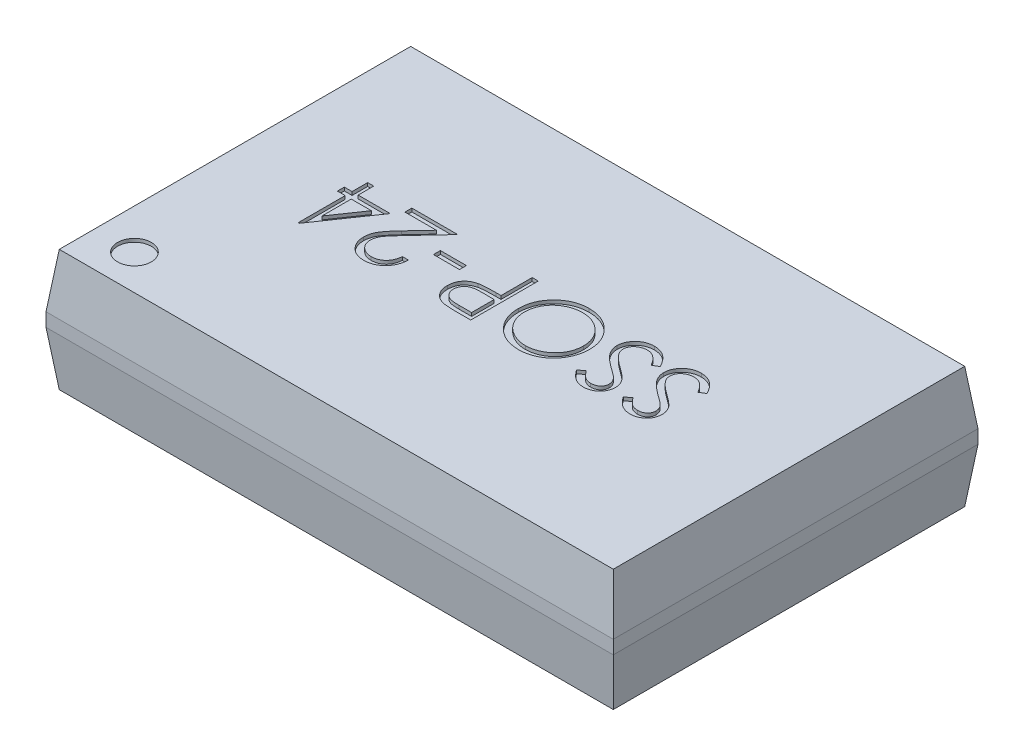
from build123d import *

# Parameters (mm, degrees)
SKETCH1_W             = 8.4
SKETCH1_H             = 5.4
EXTRUDE1_DEPTH        = 1.8
CHAMFER1_SIZE         = 0.8
CHAMFER1_SIZE2        = 0.098227649
CHAMFER1_PART_2_SIZE  = 0.8
CHAMFER1_PART_2_SIZE2 = 0.098227649
CHAMFER1_PART_3_SIZE  = 0.8
CHAMFER1_PART_3_SIZE2 = 0.098227649
CHAMFER1_PART_4_SIZE  = 0.8
CHAMFER1_PART_4_SIZE2 = 0.098227649
CHAMFER2_SIZE         = 0.8
CHAMFER2_SIZE2        = 0.098227649
CHAMFER2_PART_2_SIZE  = 0.8
CHAMFER2_PART_2_SIZE2 = 0.098227649
CHAMFER2_PART_3_SIZE  = 0.8
CHAMFER2_PART_3_SIZE2 = 0.098227649
CHAMFER2_PART_4_SIZE  = 0.8
CHAMFER2_PART_4_SIZE2 = 0.098227649
SKETCH3_R             = 0.25
CUT_EXTRUDE1_DEPTH    = 0.05
SKETCH4_W             = 0.384615385
SKETCH4_H             = 0.102564103
CUT_EXTRUDE2_DEPTH    = 0.05


with BuildPart() as part:
    # Sketch1 → Extrude1 (new body)
    with BuildSketch(Plane(origin=(0, 0, 0), x_dir=(1, 0, 0), z_dir=(0, 1, 0))):
        with Locations((4.2, 2.7)):
            Rectangle(SKETCH1_W, SKETCH1_H)
    extrude(amount=EXTRUDE1_DEPTH)

    # Chamfer1
    chamfer1_edges = [part.edges().sort_by_distance(p)[0] for p in [
        (8.4, 1.8, -2.7),
    ]]
    chamfer1_side = [part.faces().sort_by_distance(p)[0] for p in [
        (8.4, 0.9, -2.7),
    ]]
    chamfer(chamfer1_edges, length=CHAMFER1_SIZE, length2=CHAMFER1_SIZE2, reference=chamfer1_side[0])

    # Chamfer1 part 2
    chamfer1_part_2_edges = [part.edges().sort_by_distance(p)[0] for p in [
        (4.2, 1.8, -5.4),
    ]]
    chamfer1_part_2_side = [part.faces().sort_by_distance(p)[0] for p in [
        (4.2, 0.9, -5.4),
    ]]
    chamfer(chamfer1_part_2_edges, length=CHAMFER1_PART_2_SIZE, length2=CHAMFER1_PART_2_SIZE2, reference=chamfer1_part_2_side[0])

    # Chamfer1 part 3
    chamfer1_part_3_edges = [part.edges().sort_by_distance(p)[0] for p in [
        (0, 1.8, -2.7),
    ]]
    chamfer1_part_3_side = [part.faces().sort_by_distance(p)[0] for p in [
        (0, 0.9, -2.7),
    ]]
    chamfer(chamfer1_part_3_edges, length=CHAMFER1_PART_3_SIZE, length2=CHAMFER1_PART_3_SIZE2, reference=chamfer1_part_3_side[0])

    # Chamfer1 part 4
    chamfer1_part_4_edges = [part.edges().sort_by_distance(p)[0] for p in [
        (4.2, 1.8, 0),
    ]]
    chamfer1_part_4_side = [part.faces().sort_by_distance(p)[0] for p in [
        (4.2, 0.9, 0),
    ]]
    chamfer(chamfer1_part_4_edges, length=CHAMFER1_PART_4_SIZE, length2=CHAMFER1_PART_4_SIZE2, reference=chamfer1_part_4_side[0])

    # Chamfer2
    chamfer2_edges = [part.edges().sort_by_distance(p)[0] for p in [
        (4.2, 0, -5.4),
    ]]
    chamfer2_side = [part.faces().sort_by_distance(p)[0] for p in [
        (4.2, 0.5, -5.4),
    ]]
    chamfer(chamfer2_edges, length=CHAMFER2_SIZE, length2=CHAMFER2_SIZE2, reference=chamfer2_side[0])

    # Chamfer2 part 2
    chamfer2_part_2_edges = [part.edges().sort_by_distance(p)[0] for p in [
        (8.4, 0, -2.7),
    ]]
    chamfer2_part_2_side = [part.faces().sort_by_distance(p)[0] for p in [
        (8.4, 0.5, -2.7),
    ]]
    chamfer(chamfer2_part_2_edges, length=CHAMFER2_PART_2_SIZE, length2=CHAMFER2_PART_2_SIZE2, reference=chamfer2_part_2_side[0])

    # Chamfer2 part 3
    chamfer2_part_3_edges = [part.edges().sort_by_distance(p)[0] for p in [
        (4.2, 0, 0),
    ]]
    chamfer2_part_3_side = [part.faces().sort_by_distance(p)[0] for p in [
        (4.2, 0.5, 0),
    ]]
    chamfer(chamfer2_part_3_edges, length=CHAMFER2_PART_3_SIZE, length2=CHAMFER2_PART_3_SIZE2, reference=chamfer2_part_3_side[0])

    # Chamfer2 part 4
    chamfer2_part_4_edges = [part.edges().sort_by_distance(p)[0] for p in [
        (0, 0, -2.7),
    ]]
    chamfer2_part_4_side = [part.faces().sort_by_distance(p)[0] for p in [
        (0, 0.5, -2.7),
    ]]
    chamfer(chamfer2_part_4_edges, length=CHAMFER2_PART_4_SIZE, length2=CHAMFER2_PART_4_SIZE2, reference=chamfer2_part_4_side[0])

    # Sketch3 → Cut-Extrude1 (cut)
    with BuildSketch(Plane(origin=(0, 1.8, 0), x_dir=(-1, 0, 0), z_dir=(0, 1, 0))):
        with Locations(Location((-0.690878187, -0.618640227, 0), (0, 0, 90))):  # turned: the seam where the file's is
            Circle(SKETCH3_R)
    extrude(amount=-CUT_EXTRUDE1_DEPTH, mode=Mode.SUBTRACT)

    # Sketch4 → Cut-Extrude2 (cut)
    with BuildSketch(Plane(origin=(0, 1.8, 0), x_dir=(-1, 0, 0), z_dir=(0, 1, 0))):
        with BuildLine():
            Line((-6.743449311, -3.044705448), (-6.658914055, -2.994024358))
            add(Edge.make_bspline(
                [(-6.658914055, -2.994024358), (-6.651051701, -3.007185611), (-6.635987735, -3.032402063), (-6.610858776, -3.066475789), (-6.584820801, -3.095436405), (-6.557680991, -3.119115436), (-6.529605006, -3.137757975), (-6.500409562, -3.150958613), (-6.470193045, -3.159191748), (-6.449629096, -3.160191773), (-6.439362773, -3.160691024)],
                knots=[0, 0, 0, 0, 1.272034388, 2.437168799, 3.508375237, 4.49857839, 5.41946034, 6.295179144, 7.148887113, 8, 8, 8, 8], degree=3))
            add(Edge.make_bspline(
                [(-6.439362773, -3.160691024), (-6.430595098, -3.160446832), (-6.413213163, -3.159962721), (-6.387623951, -3.155311063), (-6.362772007, -3.148164741), (-6.339169539, -3.137930189), (-6.317142221, -3.125547764), (-6.297826022, -3.110591713), (-6.281127133, -3.093847083), (-6.267467386, -3.075166325), (-6.256987376, -3.055075711), (-6.248932499, -3.03445401), (-6.244462478, -3.012977277), (-6.24378912, -2.998517144), (-6.243449311, -2.991219871)],
                knots=[0, 0, 0, 0, 1.095163259, 2.171163733, 3.241058638, 4.321873601, 5.38011039, 6.391990106, 7.366004449, 8.327778327, 9.272591725, 10.192022065, 11.087607919, 12, 12, 12, 12], degree=3))
            add(Edge.make_bspline(
                [(-6.243449311, -2.991219871), (-6.243870543, -2.982893914), (-6.244726845, -2.965968459), (-6.251964411, -2.94099713), (-6.26334991, -2.916284967), (-6.273853522, -2.900998891), (-6.279306683, -2.893062819)],
                knots=[0, 0, 0, 0, 0.938893495, 1.908633276, 2.914225137, 4, 4, 4, 4], degree=3))
            add(Edge.make_bspline(
                [(-6.279306683, -2.893062819), (-6.283784001, -2.887335155), (-6.293183571, -2.875310642), (-6.30934286, -2.857412003), (-6.328304607, -2.838949597), (-6.349419909, -2.819218438), (-6.373457934, -2.799136211), (-6.399665795, -2.777745274), (-6.428712612, -2.755859109), (-6.449083897, -2.741181233), (-6.459595144, -2.733607691)],
                knots=[0, 0, 0, 0, 0.722233717, 1.516239348, 2.393582979, 3.351407094, 4.387010283, 5.505090956, 6.712668013, 8, 8, 8, 8], degree=3))
            add(Edge.make_bspline(
                [(-6.459595144, -2.733607691), (-6.470116286, -2.726113809), (-6.490231908, -2.711786077), (-6.518362932, -2.690521996), (-6.543518493, -2.67108089), (-6.565586783, -2.653279744), (-6.584558096, -2.637116142), (-6.600581928, -2.622745303), (-6.613250087, -2.609778571), (-6.620294539, -2.601366759), (-6.623457324, -2.597590063)],
                knots=[0, 0, 0, 0, 1.452282411, 2.77665338, 3.964542531, 5.026858415, 5.96415736, 6.766646006, 7.446254459, 8, 8, 8, 8], degree=3))
            add(Edge.make_bspline(
                [(-6.623457324, -2.597590063), (-6.627878051, -2.591704052), (-6.636572005, -2.580128423), (-6.648048006, -2.562035606), (-6.657802053, -2.543514673), (-6.665448433, -2.524515855), (-6.671887353, -2.505305875), (-6.67621819, -2.485634091), (-6.678930018, -2.465588771), (-6.679207728, -2.452099199), (-6.679346747, -2.445346473)],
                knots=[0, 0, 0, 0, 1.068054152, 2.10047183, 3.106115577, 4.101338837, 5.06977816, 6.043150881, 7.020423561, 8, 8, 8, 8], degree=3))
            add(Edge.make_bspline(
                [(-6.679346747, -2.445346473), (-6.67897383, -2.434766538), (-6.678235967, -2.413832805), (-6.67199582, -2.383252568), (-6.662146421, -2.354056449), (-6.648347882, -2.326533496), (-6.630560067, -2.301400359), (-6.609975503, -2.278367934), (-6.585457935, -2.259005482), (-6.558557186, -2.242087751), (-6.529112508, -2.228846058), (-6.498257964, -2.218857206), (-6.465944515, -2.213197419), (-6.444057905, -2.2123852), (-6.432952516, -2.211973076)],
                knots=[0, 0, 0, 0, 1.005424448, 1.989358655, 2.955360095, 3.929531133, 4.905563448, 5.876582895, 6.856512386, 7.866279853, 8.892233794, 9.918561126, 10.94386622, 12, 12, 12, 12], degree=3))
            add(Edge.make_bspline(
                [(-6.432952516, -2.211973076), (-6.421168488, -2.212379519), (-6.397733816, -2.213187805), (-6.363262611, -2.220215671), (-6.330073835, -2.231844435), (-6.303375759, -2.245041194), (-6.282480685, -2.258221598), (-6.266545618, -2.270227263), (-6.250397775, -2.284048722), (-6.233906902, -2.299722792), (-6.217352428, -2.317393293), (-6.200488585, -2.336939204), (-6.183275937, -2.358241077), (-6.172202834, -2.373448077), (-6.166526234, -2.381243909)],
                knots=[0, 0, 0, 0, 1.286793592, 2.559021753, 3.825965368, 5.121522368, 5.803751409, 6.523245864, 7.299691795, 8.125521123, 9.008227632, 9.944561021, 10.946284179, 12, 12, 12, 12], degree=3))
            Line((-6.166526234, -2.381243909), (-6.247656042, -2.442742306))
            add(Edge.make_bspline(
                [(-6.247656042, -2.442742306), (-6.25255488, -2.436431252), (-6.261988896, -2.424277637), (-6.276311607, -2.407257261), (-6.28981122, -2.391709695), (-6.303111335, -2.378205373), (-6.315509515, -2.366004764), (-6.327542956, -2.355559119), (-6.339038485, -2.346766092), (-6.35352903, -2.337382217), (-6.371734093, -2.328080359), (-6.394586817, -2.320209194), (-6.41846861, -2.315479176), (-6.434734219, -2.31485378), (-6.442968542, -2.314537178)],
                knots=[0, 0, 0, 0, 1.181633172, 2.275549214, 3.290209073, 4.226197932, 5.078386478, 5.862611352, 6.581680152, 7.217281963, 8.414376989, 9.595101626, 10.782541182, 12, 12, 12, 12], degree=3))
            add(Edge.make_bspline(
                [(-6.442968542, -2.314537178), (-6.453298977, -2.314883378), (-6.473220248, -2.315550992), (-6.501503172, -2.322842417), (-6.526958579, -2.334322948), (-6.548830741, -2.350412942), (-6.567041306, -2.369476083), (-6.580214294, -2.391412898), (-6.588142912, -2.415636442), (-6.589110421, -2.432534058), (-6.589603157, -2.441139742)],
                knots=[0, 0, 0, 0, 1.14458467, 2.207223713, 3.21896685, 4.227309161, 5.202851033, 6.127160689, 7.046193047, 8, 8, 8, 8], degree=3))
            add(Edge.make_bspline(
                [(-6.589603157, -2.441139742), (-6.589490835, -2.446497308), (-6.589266008, -2.457221199), (-6.586130351, -2.473064462), (-6.582101972, -2.488867702), (-6.575718363, -2.504559869), (-6.566905419, -2.5204154), (-6.555332511, -2.536707325), (-6.540757279, -2.553579242), (-6.529592419, -2.564552777), (-6.523697709, -2.570346473)],
                knots=[0, 0, 0, 0, 0.858281714, 1.717966888, 2.583508476, 3.4729293, 4.427298488, 5.488583878, 6.674047936, 8, 8, 8, 8], degree=3))
            add(Edge.make_bspline(
                [(-6.523697709, -2.570346473), (-6.521508745, -2.572299909), (-6.516308269, -2.576940826), (-6.506800861, -2.58453862), (-6.494245776, -2.593910841), (-6.478970862, -2.605507217), (-6.460694472, -2.618959063), (-6.439414599, -2.634094381), (-6.415368447, -2.651404512), (-6.398305043, -2.663506667), (-6.389282644, -2.669905768)],
                knots=[0, 0, 0, 0, 0.420754252, 0.999615792, 1.744751191, 2.668019286, 3.750313428, 4.999500688, 6.413464383, 8, 8, 8, 8], degree=3))
            add(Edge.make_bspline(
                [(-6.389282644, -2.669905768), (-6.378429526, -2.677803299), (-6.357413967, -2.693095774), (-6.327511802, -2.716071683), (-6.300399285, -2.738542474), (-6.275981227, -2.760364647), (-6.254016396, -2.781372674), (-6.234748476, -2.801819297), (-6.217981139, -2.821558032), (-6.199929933, -2.846864482), (-6.181484842, -2.877944792), (-6.165644411, -2.916024288), (-6.155656312, -2.954251809), (-6.154350165, -2.97994519), (-6.153705721, -2.992622114)],
                knots=[0, 0, 0, 0, 1.163667725, 2.253281268, 3.268753668, 4.215851969, 5.092017293, 5.902905408, 6.650798638, 7.335211899, 8.59617414, 9.77448103, 10.901945474, 12, 12, 12, 12], degree=3))
            add(Edge.make_bspline(
                [(-6.153705721, -2.992622114), (-6.153893475, -3.001587361), (-6.154265337, -3.019343757), (-6.158539883, -3.045416636), (-6.164802645, -3.070739741), (-6.174241855, -3.095000059), (-6.185762757, -3.11864142), (-6.200381685, -3.141043677), (-6.217326738, -3.162702648), (-6.236764956, -3.183040789), (-6.258035214, -3.20171113), (-6.28051627, -3.218319434), (-6.304244919, -3.232167526), (-6.329092438, -3.243467767), (-6.355064534, -3.252305914), (-6.382152473, -3.258709591), (-6.410400904, -3.262639795), (-6.429601042, -3.263047726), (-6.439362773, -3.263255127)],
                knots=[0, 0, 0, 0, 0.983748083, 1.948392443, 2.894712957, 3.844097841, 4.80183111, 5.778335162, 6.776009319, 7.81870978, 8.863265674, 9.881300176, 10.883814829, 11.87499822, 12.874611388, 13.892143829, 14.928324115, 16, 16, 16, 16], degree=3))
            add(Edge.make_bspline(
                [(-6.439362773, -3.263255127), (-6.446915728, -3.263109075), (-6.461926516, -3.262818811), (-6.484129226, -3.260252731), (-6.505883394, -3.25662213), (-6.526916046, -3.25085811), (-6.547498163, -3.243864688), (-6.56754023, -3.235253735), (-6.58705196, -3.224934535), (-6.606142698, -3.213135957), (-6.624763891, -3.199405172), (-6.642740882, -3.183412745), (-6.660663506, -3.165599743), (-6.678002762, -3.14548244), (-6.695109375, -3.123385844), (-6.711646063, -3.099103221), (-6.727955126, -3.072766834), (-6.738188116, -3.054233952), (-6.743449311, -3.044705448)],
                knots=[0, 0, 0, 0, 0.915332311, 1.819136955, 2.706846663, 3.586547465, 4.459518054, 5.340707479, 6.227863349, 7.133153174, 8.059268498, 9.028702269, 10.047606654, 11.120612155, 12.245963614, 13.433783089, 14.680604001, 16, 16, 16, 16], degree=3))
        make_face()
        with BuildLine():
            Line((-6.051141619, -3.044705448), (-5.966606362, -2.994024358))
            add(Edge.make_bspline(
                [(-5.966606362, -2.994024358), (-5.958744009, -3.007185611), (-5.943680043, -3.032402063), (-5.918551083, -3.066475789), (-5.892513109, -3.095436405), (-5.865373299, -3.119115436), (-5.837297314, -3.137757975), (-5.80810187, -3.150958613), (-5.777885353, -3.159191748), (-5.757321404, -3.160191773), (-5.74705508, -3.160691024)],
                knots=[0, 0, 0, 0, 1.272034388, 2.437168799, 3.508375237, 4.49857839, 5.41946034, 6.295179144, 7.148887113, 8, 8, 8, 8], degree=3))
            add(Edge.make_bspline(
                [(-5.74705508, -3.160691024), (-5.738287406, -3.160446832), (-5.720905471, -3.159962721), (-5.695316259, -3.155311063), (-5.670464315, -3.148164741), (-5.646861847, -3.137930189), (-5.624834529, -3.125547764), (-5.60551833, -3.110591713), (-5.588819441, -3.093847083), (-5.575159693, -3.075166325), (-5.564679683, -3.055075711), (-5.556624807, -3.03445401), (-5.552154786, -3.012977277), (-5.551481428, -2.998517144), (-5.551141619, -2.991219871)],
                knots=[0, 0, 0, 0, 1.095163259, 2.171163733, 3.241058638, 4.321873601, 5.38011039, 6.391990106, 7.366004449, 8.327778327, 9.272591725, 10.192022065, 11.087607919, 12, 12, 12, 12], degree=3))
            add(Edge.make_bspline(
                [(-5.551141619, -2.991219871), (-5.55156285, -2.982893914), (-5.552419153, -2.965968459), (-5.559656719, -2.94099713), (-5.571042218, -2.916284967), (-5.58154583, -2.900998891), (-5.586998991, -2.893062819)],
                knots=[0, 0, 0, 0, 0.938893495, 1.908633276, 2.914225137, 4, 4, 4, 4], degree=3))
            add(Edge.make_bspline(
                [(-5.586998991, -2.893062819), (-5.591476309, -2.887335155), (-5.600875879, -2.875310642), (-5.617035168, -2.857412003), (-5.635996915, -2.838949597), (-5.657112216, -2.819218438), (-5.681150242, -2.799136211), (-5.707358103, -2.777745274), (-5.73640492, -2.755859109), (-5.756776205, -2.741181233), (-5.767287452, -2.733607691)],
                knots=[0, 0, 0, 0, 0.722233717, 1.516239348, 2.393582979, 3.351407094, 4.387010283, 5.505090956, 6.712668013, 8, 8, 8, 8], degree=3))
            add(Edge.make_bspline(
                [(-5.767287452, -2.733607691), (-5.777808594, -2.726113809), (-5.797924216, -2.711786077), (-5.826055239, -2.690521996), (-5.8512108, -2.67108089), (-5.873279091, -2.653279744), (-5.892250404, -2.637116142), (-5.908274236, -2.622745303), (-5.920942395, -2.609778571), (-5.927986847, -2.601366759), (-5.931149632, -2.597590063)],
                knots=[0, 0, 0, 0, 1.452282411, 2.77665338, 3.964542531, 5.026858415, 5.96415736, 6.766646006, 7.446254459, 8, 8, 8, 8], degree=3))
            add(Edge.make_bspline(
                [(-5.931149632, -2.597590063), (-5.935570359, -2.591704052), (-5.944264312, -2.580128423), (-5.955740314, -2.562035606), (-5.96549436, -2.543514673), (-5.973140741, -2.524515855), (-5.979579661, -2.505305875), (-5.983910498, -2.485634091), (-5.986622326, -2.465588771), (-5.986900036, -2.452099199), (-5.987039055, -2.445346473)],
                knots=[0, 0, 0, 0, 1.068054152, 2.10047183, 3.106115577, 4.101338837, 5.06977816, 6.043150881, 7.020423561, 8, 8, 8, 8], degree=3))
            add(Edge.make_bspline(
                [(-5.987039055, -2.445346473), (-5.986666138, -2.434766538), (-5.985928275, -2.413832805), (-5.979688127, -2.383252568), (-5.969838729, -2.354056449), (-5.95604019, -2.326533496), (-5.938252375, -2.301400359), (-5.91766781, -2.278367934), (-5.893150243, -2.259005482), (-5.866249493, -2.242087751), (-5.836804816, -2.228846058), (-5.805950272, -2.218857206), (-5.773636823, -2.213197419), (-5.751750213, -2.2123852), (-5.740644824, -2.211973076)],
                knots=[0, 0, 0, 0, 1.005424448, 1.989358655, 2.955360095, 3.929531133, 4.905563448, 5.876582895, 6.856512386, 7.866279853, 8.892233794, 9.918561126, 10.94386622, 12, 12, 12, 12], degree=3))
            add(Edge.make_bspline(
                [(-5.740644824, -2.211973076), (-5.728860795, -2.212379519), (-5.705426123, -2.213187805), (-5.670954919, -2.220215671), (-5.637766143, -2.231844435), (-5.611068067, -2.245041194), (-5.590172992, -2.258221598), (-5.574237926, -2.270227263), (-5.558090083, -2.284048722), (-5.54159921, -2.299722792), (-5.525044736, -2.317393293), (-5.508180892, -2.336939204), (-5.490968244, -2.358241077), (-5.479895141, -2.373448077), (-5.474218542, -2.381243909)],
                knots=[0, 0, 0, 0, 1.286793592, 2.559021753, 3.825965368, 5.121522368, 5.803751409, 6.523245864, 7.299691795, 8.125521123, 9.008227632, 9.944561021, 10.946284179, 12, 12, 12, 12], degree=3))
            Line((-5.474218542, -2.381243909), (-5.55534835, -2.442742306))
            add(Edge.make_bspline(
                [(-5.55534835, -2.442742306), (-5.560247187, -2.436431252), (-5.569681204, -2.424277637), (-5.584003914, -2.407257261), (-5.597503528, -2.391709695), (-5.610803642, -2.378205373), (-5.623201823, -2.366004764), (-5.635235263, -2.355559119), (-5.646730792, -2.346766092), (-5.661221338, -2.337382217), (-5.6794264, -2.328080359), (-5.702279125, -2.320209194), (-5.726160918, -2.315479176), (-5.742426527, -2.31485378), (-5.75066085, -2.314537178)],
                knots=[0, 0, 0, 0, 1.181633172, 2.275549214, 3.290209073, 4.226197932, 5.078386478, 5.862611352, 6.581680152, 7.217281963, 8.414376989, 9.595101626, 10.782541182, 12, 12, 12, 12], degree=3))
            add(Edge.make_bspline(
                [(-5.75066085, -2.314537178), (-5.760991285, -2.314883378), (-5.780912555, -2.315550992), (-5.80919548, -2.322842417), (-5.834650887, -2.334322948), (-5.856523048, -2.350412942), (-5.874733613, -2.369476083), (-5.887906602, -2.391412898), (-5.89583522, -2.415636442), (-5.896802728, -2.432534058), (-5.897295465, -2.441139742)],
                knots=[0, 0, 0, 0, 1.14458467, 2.207223713, 3.21896685, 4.227309161, 5.202851033, 6.127160689, 7.046193047, 8, 8, 8, 8], degree=3))
            add(Edge.make_bspline(
                [(-5.897295465, -2.441139742), (-5.897183143, -2.446497308), (-5.896958316, -2.457221199), (-5.893822659, -2.473064462), (-5.889794279, -2.488867702), (-5.88341067, -2.504559869), (-5.874597726, -2.5204154), (-5.863024819, -2.536707325), (-5.848449587, -2.553579242), (-5.837284726, -2.564552777), (-5.831390016, -2.570346473)],
                knots=[0, 0, 0, 0, 0.858281714, 1.717966888, 2.583508476, 3.4729293, 4.427298488, 5.488583878, 6.674047936, 8, 8, 8, 8], degree=3))
            add(Edge.make_bspline(
                [(-5.831390016, -2.570346473), (-5.829201053, -2.572299909), (-5.824000576, -2.576940826), (-5.814493169, -2.58453862), (-5.801938084, -2.593910841), (-5.786663169, -2.605507217), (-5.76838678, -2.618959063), (-5.747106907, -2.634094381), (-5.723060755, -2.651404512), (-5.70599735, -2.663506667), (-5.696974952, -2.669905768)],
                knots=[0, 0, 0, 0, 0.420754252, 0.999615792, 1.744751191, 2.668019286, 3.750313428, 4.999500688, 6.413464383, 8, 8, 8, 8], degree=3))
            add(Edge.make_bspline(
                [(-5.696974952, -2.669905768), (-5.686121834, -2.677803299), (-5.665106275, -2.693095774), (-5.635204109, -2.716071683), (-5.608091593, -2.738542474), (-5.583673535, -2.760364647), (-5.561708704, -2.781372674), (-5.542440784, -2.801819297), (-5.525673446, -2.821558032), (-5.507622241, -2.846864482), (-5.48917715, -2.877944792), (-5.473336719, -2.916024288), (-5.46334862, -2.954251809), (-5.462042472, -2.97994519), (-5.461398029, -2.992622114)],
                knots=[0, 0, 0, 0, 1.163667725, 2.253281268, 3.268753668, 4.215851969, 5.092017293, 5.902905408, 6.650798638, 7.335211899, 8.59617414, 9.77448103, 10.901945474, 12, 12, 12, 12], degree=3))
            add(Edge.make_bspline(
                [(-5.461398029, -2.992622114), (-5.461585783, -3.001587361), (-5.461957644, -3.019343757), (-5.466232191, -3.045416636), (-5.472494953, -3.070739741), (-5.481934162, -3.095000059), (-5.493455065, -3.11864142), (-5.508073993, -3.141043677), (-5.525019045, -3.162702648), (-5.544457264, -3.183040789), (-5.565727522, -3.20171113), (-5.588208577, -3.218319434), (-5.611937227, -3.232167526), (-5.636784746, -3.243467767), (-5.662756842, -3.252305914), (-5.68984478, -3.258709591), (-5.718093212, -3.262639795), (-5.73729335, -3.263047726), (-5.74705508, -3.263255127)],
                knots=[0, 0, 0, 0, 0.983748083, 1.948392443, 2.894712957, 3.844097841, 4.80183111, 5.778335162, 6.776009319, 7.81870978, 8.863265674, 9.881300176, 10.883814829, 11.87499822, 12.874611388, 13.892143829, 14.928324115, 16, 16, 16, 16], degree=3))
            add(Edge.make_bspline(
                [(-5.74705508, -3.263255127), (-5.754608036, -3.263109075), (-5.769618824, -3.262818811), (-5.791821533, -3.260252731), (-5.813575702, -3.25662213), (-5.834608354, -3.25085811), (-5.855190471, -3.243864688), (-5.875232538, -3.235253735), (-5.894744268, -3.224934535), (-5.913835006, -3.213135957), (-5.932456199, -3.199405172), (-5.950433189, -3.183412745), (-5.968355814, -3.165599743), (-5.98569507, -3.14548244), (-6.002801683, -3.123385844), (-6.019338371, -3.099103221), (-6.035647433, -3.072766834), (-6.045880424, -3.054233952), (-6.051141619, -3.044705448)],
                knots=[0, 0, 0, 0, 0.915332311, 1.819136955, 2.706846663, 3.586547465, 4.459518054, 5.340707479, 6.227863349, 7.133153174, 8.059268498, 9.028702269, 10.047606654, 11.120612155, 12.245963614, 13.433783089, 14.680604001, 16, 16, 16, 16], degree=3))
        make_face()
        with BuildLine():
            add(Edge.make_bspline(
                [(-4.788321106, -2.211973076), (-4.769804504, -2.21244207), (-4.733436371, -2.213363213), (-4.6799864, -2.220414385), (-4.62895923, -2.232613068), (-4.57993919, -2.248859635), (-4.533512626, -2.270532316), (-4.489330085, -2.296728073), (-4.447496692, -2.327721347), (-4.408576298, -2.363272554), (-4.372960026, -2.401953541), (-4.341581202, -2.443232944), (-4.315283403, -2.486861173), (-4.293687464, -2.532707125), (-4.276745004, -2.580667116), (-4.265053849, -2.630996831), (-4.257585806, -2.683370171), (-4.256712727, -2.719092132), (-4.256269824, -2.73721346)],
                knots=[0, 0, 0, 0, 1.065120563, 2.091984664, 3.0946048, 4.079830382, 5.057816894, 6.036188127, 7.030412546, 8.04752943, 9.064399622, 10.05169764, 11.02544977, 11.989514704, 12.962713494, 13.945757189, 14.957906945, 16, 16, 16, 16], degree=3))
            add(Edge.make_bspline(
                [(-4.256269824, -2.73721346), (-4.256712662, -2.755201302), (-4.257585547, -2.790657422), (-4.26506234, -2.842698406), (-4.27678834, -2.89272432), (-4.29353013, -2.940651649), (-4.315023124, -2.986530953), (-4.34149603, -3.030241511), (-4.372679233, -3.071797654), (-4.408166905, -3.110744129), (-4.446852917, -3.146457692), (-4.488347279, -3.177577371), (-4.531716799, -3.204355692), (-4.577519573, -3.225722456), (-4.625148155, -3.242800148), (-4.675028819, -3.254443757), (-4.726927834, -3.26195434), (-4.762319549, -3.262816774), (-4.780308286, -3.263255127)],
                knots=[0, 0, 0, 0, 1.043624062, 2.057103931, 3.04512605, 4.022047818, 4.998200453, 5.980619268, 6.982898556, 8.009068085, 9.034988726, 10.034168286, 11.015286542, 11.987931943, 12.962482838, 13.94673481, 14.956375938, 16, 16, 16, 16], degree=3))
            add(Edge.make_bspline(
                [(-4.780308286, -3.263255127), (-4.79842952, -3.262812445), (-4.834151295, -3.261939801), (-4.886590448, -3.2544594), (-4.936955518, -3.242761884), (-4.985102476, -3.226044903), (-5.03105817, -3.204439979), (-5.074912479, -3.178095871), (-5.116489378, -3.146836688), (-5.155444163, -3.111360524), (-5.191086791, -3.07274008), (-5.222160898, -3.031358865), (-5.248510931, -2.988028734), (-5.270043312, -2.942629442), (-5.2870903, -2.895380458), (-5.298720248, -2.845966607), (-5.306244806, -2.794669606), (-5.307111905, -2.759743063), (-5.307551875, -2.742021153)],
                knots=[0, 0, 0, 0, 1.053102029, 2.075944431, 3.073151272, 4.055350789, 5.033113405, 6.020478099, 7.024410459, 8.052272461, 9.079885166, 10.07527673, 11.055994387, 12.023226415, 12.992069828, 13.970394897, 14.97016774, 16, 16, 16, 16], degree=3))
            add(Edge.make_bspline(
                [(-5.307551875, -2.742021153), (-5.307399122, -2.730126104), (-5.307095543, -2.706486069), (-5.303440774, -2.671381326), (-5.298137431, -2.636841138), (-5.290536884, -2.602963724), (-5.280596408, -2.569832015), (-5.268867257, -2.537217511), (-5.254541587, -2.505450733), (-5.238347116, -2.474381192), (-5.220272314, -2.444493219), (-5.200307814, -2.41624191), (-5.179154852, -2.389390196), (-5.155965311, -2.364633909), (-5.131503469, -2.341252865), (-5.105372504, -2.319606374), (-5.077731863, -2.299499245), (-5.048462612, -2.281379148), (-5.018285962, -2.264990824), (-4.987178311, -2.250927438), (-4.955562148, -2.238857134), (-4.923289391, -2.229074042), (-4.890445742, -2.221350603), (-4.856959518, -2.216091359), (-4.822857396, -2.212427268), (-4.799882733, -2.212125125), (-4.788321106, -2.211973076)],
                knots=[0, 0, 0, 0, 1.037015668, 2.060948919, 3.074880161, 4.083647147, 5.086022904, 6.090072063, 7.104153813, 8.122640571, 9.144368836, 10.147691507, 11.138137339, 12.123020368, 13.103399296, 14.087645067, 15.080126199, 16.082011238, 17.087798457, 18.072939717, 19.057185487, 20.037253025, 21.01195951, 21.997135196, 22.992090687, 24, 24, 24, 24], degree=3))
        make_face()
        with BuildLine():
            add(Edge.make_bspline(
                [(-4.783914055, -2.314537178), (-4.79340395, -2.314652861), (-4.812293017, -2.314883121), (-4.840374313, -2.317916183), (-4.868086294, -2.322239008), (-4.895434683, -2.328405157), (-4.922305051, -2.336806315), (-4.948947863, -2.346475146), (-4.975120164, -2.3582526), (-5.000735552, -2.371559087), (-5.025568431, -2.38628735), (-5.049000631, -2.402564998), (-5.071092815, -2.420010299), (-5.091790891, -2.438663967), (-5.111034083, -2.458620996), (-5.129201141, -2.479578835), (-5.145563879, -2.502136518), (-5.160559758, -2.525682349), (-5.173979141, -2.550185658), (-5.185912099, -2.575388475), (-5.195673244, -2.601496386), (-5.203633923, -2.628226145), (-5.210233869, -2.655535419), (-5.214414991, -2.683631376), (-5.217481379, -2.712372837), (-5.217698478, -2.731796224), (-5.217808286, -2.741620512)],
                knots=[0, 0, 0, 0, 1.008559885, 2.007477868, 2.99961109, 3.989939068, 4.984837346, 5.991145699, 7.001802488, 8.033829008, 9.059044045, 10.069351652, 11.065060232, 12.050310815, 13.029377138, 14.011219647, 14.996725999, 15.989392538, 16.977580475, 17.965360261, 18.951710183, 19.937753436, 20.929683414, 21.935841486, 22.955955122, 24, 24, 24, 24], degree=3))
            add(Edge.make_bspline(
                [(-5.217808286, -2.741620512), (-5.217444039, -2.75606686), (-5.216727454, -2.784487298), (-5.210453863, -2.826135339), (-5.200790441, -2.866160563), (-5.18654548, -2.904343966), (-5.168731018, -2.941013761), (-5.146723335, -2.975844648), (-5.120649311, -3.008846041), (-5.09103116, -3.039787546), (-5.058653244, -3.068029205), (-5.024272464, -3.09281875), (-4.988257148, -3.113793107), (-4.950513376, -3.130880271), (-4.91124265, -3.144420196), (-4.870191921, -3.153699805), (-4.827634647, -3.159807078), (-4.798625889, -3.160393579), (-4.783914055, -3.160691024)],
                knots=[0, 0, 0, 0, 1.032063989, 2.030389145, 3.003944642, 3.970395727, 4.937377036, 5.913328081, 6.909231446, 7.93887556, 8.970685674, 9.976071282, 10.964166581, 11.944589148, 12.933237628, 13.927779006, 14.949070134, 16, 16, 16, 16], degree=3))
            add(Edge.make_bspline(
                [(-4.783914055, -3.160691024), (-4.774025626, -3.160555166), (-4.754413901, -3.160285718), (-4.725243752, -3.15757181), (-4.69659912, -3.153219848), (-4.668520183, -3.146953946), (-4.641038808, -3.139111887), (-4.614040293, -3.129795393), (-4.58781221, -3.118172192), (-4.562023685, -3.10532992), (-4.537339044, -3.090689875), (-4.513774607, -3.07496469), (-4.491924327, -3.057545084), (-4.471241735, -3.039168566), (-4.451919538, -3.01946461), (-4.4340884, -2.998458832), (-4.417808362, -2.976018644), (-4.402818177, -2.952508528), (-4.389445816, -2.92793817), (-4.377794645, -2.902643977), (-4.367910041, -2.876688231), (-4.359930468, -2.850033496), (-4.353677479, -2.822730397), (-4.34936893, -2.794742374), (-4.346355091, -2.766125419), (-4.346127926, -2.746770032), (-4.346013414, -2.73701314)],
                knots=[0, 0, 0, 0, 1.047197238, 2.076906641, 3.100256066, 4.114471768, 5.12198147, 6.126382909, 7.136867548, 8.15857795, 9.17633901, 10.174870724, 11.156907918, 12.133735059, 13.104061851, 14.077631395, 15.04955518, 16.038496417, 17.029181396, 18.010275684, 18.986308667, 19.968651475, 20.955262928, 21.950658345, 22.966943676, 24, 24, 24, 24], degree=3))
            add(Edge.make_bspline(
                [(-4.346013414, -2.73701314), (-4.346128017, -2.727322996), (-4.346355355, -2.70810081), (-4.349367491, -2.679683433), (-4.353682031, -2.651896801), (-4.359899947, -2.624850001), (-4.367914277, -2.598536136), (-4.377796371, -2.572979923), (-4.389449314, -2.548086153), (-4.402823092, -2.523916353), (-4.417856185, -2.500723571), (-4.434283112, -2.478551453), (-4.452387497, -2.457816384), (-4.471652075, -2.438006472), (-4.492558042, -2.419544218), (-4.515010698, -2.402423497), (-4.538737463, -2.386231133), (-4.56385953, -2.37162383), (-4.589786374, -2.358134049), (-4.616390362, -2.34657662), (-4.643370105, -2.336756014), (-4.670656994, -2.328379738), (-4.698480702, -2.322263158), (-4.726653225, -2.317912287), (-4.755135584, -2.314884177), (-4.77429079, -2.314653211), (-4.783914055, -2.314537178)],
                knots=[0, 0, 0, 0, 1.02996197, 2.043119294, 3.035359645, 4.018872909, 4.991431989, 5.957985074, 6.929999688, 7.912076566, 8.892894881, 9.867085534, 10.843653904, 11.817741046, 12.803660682, 13.806313499, 14.818574707, 15.856120519, 16.894564902, 17.924820532, 18.937903209, 19.946497019, 20.957711757, 21.963978472, 22.977135795, 24, 24, 24, 24], degree=3))
        make_face(mode=Mode.SUBTRACT)
        with BuildLine():
            Line((-4.051141619, -2.237614101), (-3.855027837, -2.237614101))
            add(Edge.make_bspline(
                [(-3.855027837, -2.237614101), (-3.841539006, -2.237628929), (-3.815693809, -2.237657339), (-3.778632364, -2.238518695), (-3.744972441, -2.239669178), (-3.714786618, -2.241264005), (-3.687982018, -2.243148745), (-3.664679933, -2.245792185), (-3.644697202, -2.248552269), (-3.632723931, -2.251358386), (-3.627263414, -2.25263814)],
                knots=[0, 0, 0, 0, 1.415646017, 2.712440637, 3.8905458, 4.950247383, 5.884950622, 6.709939814, 7.411656543, 8, 8, 8, 8], degree=3))
            add(Edge.make_bspline(
                [(-3.627263414, -2.25263814), (-3.620350975, -2.254530125), (-3.606688982, -2.258269515), (-3.58700297, -2.26575915), (-3.5682733, -2.274639768), (-3.550435711, -2.284760894), (-3.533709402, -2.29655677), (-3.517844819, -2.309549232), (-3.502981967, -2.324038251), (-3.489204427, -2.33986132), (-3.476551627, -2.356752808), (-3.465657432, -2.374964874), (-3.456535368, -2.394190961), (-3.448711576, -2.414417695), (-3.443080589, -2.435814931), (-3.438838617, -2.458233991), (-3.436146152, -2.481672474), (-3.435888278, -2.497689579), (-3.435757003, -2.505843268)],
                knots=[0, 0, 0, 0, 0.999701418, 1.975846123, 2.934577507, 3.890451536, 4.834027766, 5.787354733, 6.749476667, 7.726910423, 8.712836071, 9.690891519, 10.682875813, 11.679750201, 12.712814741, 13.765529915, 14.8625177, 16, 16, 16, 16], degree=3))
            add(Edge.make_bspline(
                [(-3.435757003, -2.505843268), (-3.435877411, -2.51406549), (-3.436112995, -2.530152823), (-3.438940505, -2.553687905), (-3.442749131, -2.576178873), (-3.448605432, -2.597575859), (-3.456275624, -2.617751794), (-3.465273354, -2.637015003), (-3.476125791, -2.655037766), (-3.488595742, -2.671885514), (-3.502467626, -2.687574061), (-3.517682752, -2.701989716), (-3.534179692, -2.715048099), (-3.55190602, -2.726778482), (-3.571034549, -2.736908848), (-3.591275164, -2.745982364), (-3.612803797, -2.753602667), (-3.627701658, -2.757611256), (-3.635276234, -2.759649358)],
                knots=[0, 0, 0, 0, 1.121902311, 2.195077645, 3.232258892, 4.234102512, 5.217864754, 6.176164875, 7.132989551, 8.084763148, 9.034132444, 9.988522005, 10.94243251, 11.903244335, 12.886203696, 13.894208494, 14.929344452, 16, 16, 16, 16], degree=3))
            add(Edge.make_bspline(
                [(-3.635276234, -2.759649358), (-3.641541187, -2.760981638), (-3.655271195, -2.763901408), (-3.677883401, -2.767160967), (-3.704210654, -2.769943139), (-3.73421702, -2.772029178), (-3.767875564, -2.773814997), (-3.805204495, -2.775234453), (-3.846277088, -2.776014411), (-3.874926015, -2.776054638), (-3.889883606, -2.77607564)],
                knots=[0, 0, 0, 0, 0.601384939, 1.31797006, 2.144135048, 3.087295005, 4.142315834, 5.309527816, 6.595305764, 8, 8, 8, 8], degree=3))
            Line((-3.889883606, -2.77607564), (-3.961398029, -2.77607564))
            Line((-3.961398029, -2.77607564), (-3.961398029, -3.237614101))
            Line((-3.961398029, -3.237614101), (-4.051141619, -3.237614101))
            Line((-4.051141619, -3.237614101), (-4.051141619, -2.237614101))
        make_face()
        with BuildLine():
            Line((-3.961398029, -2.340178204), (-3.961398029, -2.673511537))
            Line((-3.961398029, -2.673511537), (-3.786317901, -2.675715063))
            add(Edge.make_bspline(
                [(-3.786317901, -2.675715063), (-3.777769351, -2.675719481), (-3.761266551, -2.67572801), (-3.73742763, -2.674589375), (-3.715310691, -2.673274937), (-3.694983669, -2.671350388), (-3.676437402, -2.668630028), (-3.659640965, -2.665883817), (-3.644724599, -2.661910857), (-3.627267684, -2.656561408), (-3.607815299, -2.647437804), (-3.586653142, -2.634194978), (-3.568718689, -2.617314776), (-3.553199176, -2.598335395), (-3.54088321, -2.577221358), (-3.531867213, -2.554630234), (-3.526569739, -2.530793705), (-3.525859398, -2.514482808), (-3.525500593, -2.506243909)],
                knots=[0, 0, 0, 0, 1.160613943, 2.240541288, 3.23993089, 4.169200891, 5.011653406, 5.7853311, 6.478053781, 7.106038997, 8.262395093, 9.384106736, 10.481365981, 11.59014053, 12.70357646, 13.786202915, 14.881775077, 16, 16, 16, 16], degree=3))
            add(Edge.make_bspline(
                [(-3.525500593, -2.506243909), (-3.525861349, -2.498204334), (-3.526578488, -2.482222653), (-3.531908735, -2.45880015), (-3.540865681, -2.436447092), (-3.553281851, -2.415597639), (-3.568350745, -2.396686552), (-3.585864844, -2.380258801), (-3.605782918, -2.367052601), (-3.624310984, -2.358528806), (-3.640768466, -2.353324441), (-3.655063312, -2.349683058), (-3.671203504, -2.346775742), (-3.689194298, -2.344421599), (-3.708896251, -2.342406324), (-3.730478627, -2.341038902), (-3.753859668, -2.340238486), (-3.770091259, -2.340198784), (-3.778505401, -2.340178204)],
                knots=[0, 0, 0, 0, 1.120700087, 2.227813068, 3.331159281, 4.466773991, 5.599788987, 6.693661531, 7.80175334, 8.91857717, 9.525282508, 10.207424825, 10.974604443, 11.810962634, 12.737642355, 13.736264703, 14.826523623, 16, 16, 16, 16], degree=3))
            Line((-3.778505401, -2.340178204), (-3.961398029, -2.340178204))
        make_face(mode=Mode.SUBTRACT)
        with Locations((-3.128064695, -2.852998717)):
            Rectangle(SKETCH4_W, SKETCH4_H)
        with BuildLine():
            Line((-2.730628798, -2.545306409), (-2.820372388, -2.545306409))
            add(Edge.make_bspline(
                [(-2.820372388, -2.545306409), (-2.819787487, -2.533400441), (-2.818638757, -2.510017437), (-2.813259246, -2.475924892), (-2.805561853, -2.443337807), (-2.79467858, -2.412517831), (-2.781162501, -2.383192458), (-2.764953922, -2.355478168), (-2.745755679, -2.329480685), (-2.723982326, -2.305441016), (-2.700334143, -2.283387424), (-2.674818161, -2.264343069), (-2.648005296, -2.248252306), (-2.619976896, -2.234800522), (-2.590416735, -2.224703424), (-2.559593061, -2.217211527), (-2.527370451, -2.212703999), (-2.505416159, -2.212219489), (-2.494250593, -2.211973076)],
                knots=[0, 0, 0, 0, 1.10065271, 2.161652631, 3.183658789, 4.190468796, 5.17591951, 6.163126047, 7.15150782, 8.156236427, 9.156009102, 10.134482811, 11.092018607, 12.041330605, 13.001268258, 13.972401359, 14.968799086, 16, 16, 16, 16], degree=3))
            add(Edge.make_bspline(
                [(-2.494250593, -2.211973076), (-2.483285429, -2.212229778), (-2.461739274, -2.212734188), (-2.430292984, -2.21706591), (-2.400356614, -2.223850365), (-2.371988681, -2.233369055), (-2.345415519, -2.246164606), (-2.320437507, -2.261535331), (-2.296757275, -2.279312426), (-2.275441051, -2.300242087), (-2.255867314, -2.322585625), (-2.238980955, -2.346439312), (-2.224520052, -2.371076251), (-2.212466429, -2.396684308), (-2.203593246, -2.423504602), (-2.196856615, -2.45114666), (-2.193048783, -2.479896606), (-2.192464376, -2.499355622), (-2.19216726, -2.509248717)],
                knots=[0, 0, 0, 0, 1.111607364, 2.184268762, 3.212621178, 4.221274766, 5.211760367, 6.196651075, 7.1921475, 8.207485113, 9.220403448, 10.201281604, 11.166441695, 12.114753415, 13.065576456, 14.026450734, 14.996634279, 16, 16, 16, 16], degree=3))
            add(Edge.make_bspline(
                [(-2.19216726, -2.509248717), (-2.192651049, -2.523176669), (-2.193610138, -2.550788159), (-2.201814246, -2.591363834), (-2.214627535, -2.63067624), (-2.230055351, -2.662315469), (-2.245618906, -2.687810753), (-2.259643909, -2.708801811), (-2.276062426, -2.731403374), (-2.295113425, -2.755539756), (-2.316402817, -2.781400014), (-2.340123436, -2.808968527), (-2.36644443, -2.837960462), (-2.384918288, -2.857762062), (-2.394490978, -2.868022755)],
                knots=[0, 0, 0, 0, 1.184426356, 2.348067706, 3.509069118, 4.696110526, 5.333549288, 6.050745305, 6.844228056, 7.710549037, 8.667450064, 9.695053472, 10.805634456, 12, 12, 12, 12], degree=3))
            Line((-2.394490978, -2.868022755), (-2.644691298, -3.135049999))
            Line((-2.644691298, -3.135049999), (-2.179346747, -3.135049999))
            Line((-2.179346747, -3.135049999), (-2.179346747, -3.237614101))
            Line((-2.179346747, -3.237614101), (-2.858833927, -3.237614101))
            Line((-2.858833927, -3.237614101), (-2.471013414, -2.823751922))
            add(Edge.make_bspline(
                [(-2.471013414, -2.823751922), (-2.46157116, -2.813895263), (-2.443434524, -2.794962638), (-2.417782359, -2.767321792), (-2.394742648, -2.741679066), (-2.37416625, -2.71808291), (-2.356499535, -2.696188176), (-2.340821754, -2.676703975), (-2.328260157, -2.658774132), (-2.314627186, -2.6379911), (-2.301423192, -2.612616152), (-2.290076804, -2.581606526), (-2.283158276, -2.549684454), (-2.282328323, -2.528112444), (-2.28191085, -2.517261537)],
                knots=[0, 0, 0, 0, 1.329631726, 2.553950428, 3.673215718, 4.687767853, 5.603093632, 6.413772471, 7.123043292, 7.734684054, 8.834405432, 9.900288307, 10.943827018, 12, 12, 12, 12], degree=3))
            add(Edge.make_bspline(
                [(-2.28191085, -2.517261537), (-2.28209249, -2.510438281), (-2.282450469, -2.496990952), (-2.285609811, -2.477275021), (-2.290384242, -2.458256503), (-2.297225744, -2.439876897), (-2.306256241, -2.422320996), (-2.317248635, -2.405567431), (-2.329931511, -2.389370583), (-2.344603302, -2.374183927), (-2.360720879, -2.360275011), (-2.377747807, -2.347953844), (-2.395762123, -2.337656955), (-2.414687872, -2.329215956), (-2.434472292, -2.322594418), (-2.455153648, -2.318006253), (-2.476674795, -2.315125543), (-2.49137008, -2.31473578), (-2.498857965, -2.314537178)],
                knots=[0, 0, 0, 0, 0.991446411, 1.95395049, 2.89581595, 3.838931463, 4.798493298, 5.75982156, 6.748411868, 7.785213223, 8.824556874, 9.840280684, 10.836137867, 11.835679398, 12.848801643, 13.863922112, 14.911575587, 16, 16, 16, 16], degree=3))
            add(Edge.make_bspline(
                [(-2.498857965, -2.314537178), (-2.506678203, -2.314741473), (-2.522035859, -2.315142675), (-2.544584154, -2.31794915), (-2.566094376, -2.322790819), (-2.586620634, -2.329412726), (-2.606197659, -2.337829454), (-2.624730243, -2.34831281), (-2.642176783, -2.360822379), (-2.658570075, -2.375005395), (-2.673674069, -2.390796138), (-2.686944605, -2.408398985), (-2.698540038, -2.427492532), (-2.708656961, -2.448025261), (-2.716872873, -2.470183484), (-2.723150916, -2.493888542), (-2.728118586, -2.519037509), (-2.729778164, -2.536404676), (-2.730628798, -2.545306409)],
                knots=[0, 0, 0, 0, 1.031018746, 2.02475058, 2.990194455, 3.934040569, 4.864654155, 5.795059489, 6.735614925, 7.690564532, 8.649604399, 9.611025574, 10.590972636, 11.591080095, 12.624614302, 13.701020113, 14.821632451, 16, 16, 16, 16], degree=3))
        make_face()
        Polygon((-1.54372976, -2.211973076), (-1.525500593, -2.211973076), (-1.525500593, -2.904280768), (-1.410115978, -2.904280768), (-1.410115978, -3.006844871), (-1.525500593, -3.006844871), (-1.525500593, -3.237614101), (-1.615244183, -3.237614101), (-1.615244183, -3.006844871), (-2.089603157, -3.006844871), align=None)
        Polygon((-1.615244183, -2.904280768), (-1.615244183, -2.469985896), (-1.913321106, -2.904280768), align=None, mode=Mode.SUBTRACT)
    extrude(amount=-CUT_EXTRUDE2_DEPTH, mode=Mode.SUBTRACT)


solid = part.part
